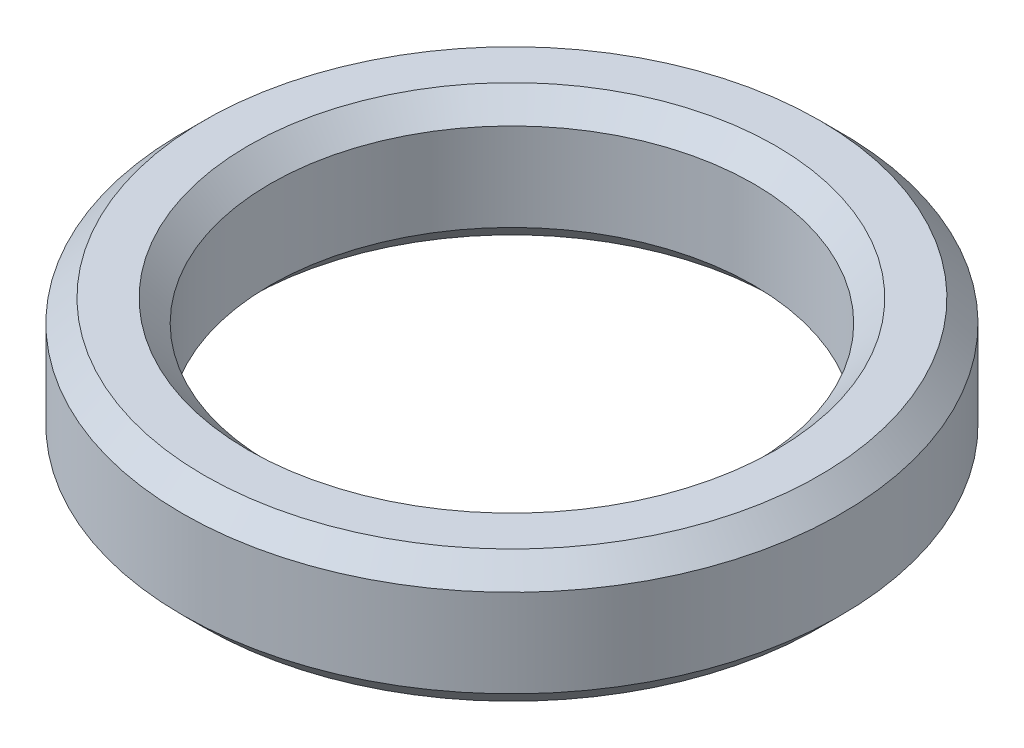
from build123d import *

# Parameters (mm, degrees)
SKETCH_1_R      = 7.5
SKETCH_1_R_2    = 5.5
EXTRUDE_1_DEPTH = 3
CHAMFER_1_SIZE  = 0.5


with BuildPart() as part:
    # 草图1 → 凸台-拉伸1 (new body)
    with BuildSketch(Plane(origin=(0, 0, 0), x_dir=(1, 0, 0), z_dir=(0, 1, 0))):
        Circle(SKETCH_1_R)
        Circle(SKETCH_1_R_2, mode=Mode.SUBTRACT)
    extrude(amount=EXTRUDE_1_DEPTH)

    # 倒角1
    chamfer_1_edges = [part.edges().sort_by_distance(p)[0] for p in [
        (-7.5, 0, 0),
        (-7.5, 3, 0),
        (-5.5, 0, 0),
        (-5.5, 3, 0),
    ]]
    chamfer(chamfer_1_edges, length=CHAMFER_1_SIZE)


solid = part.part
